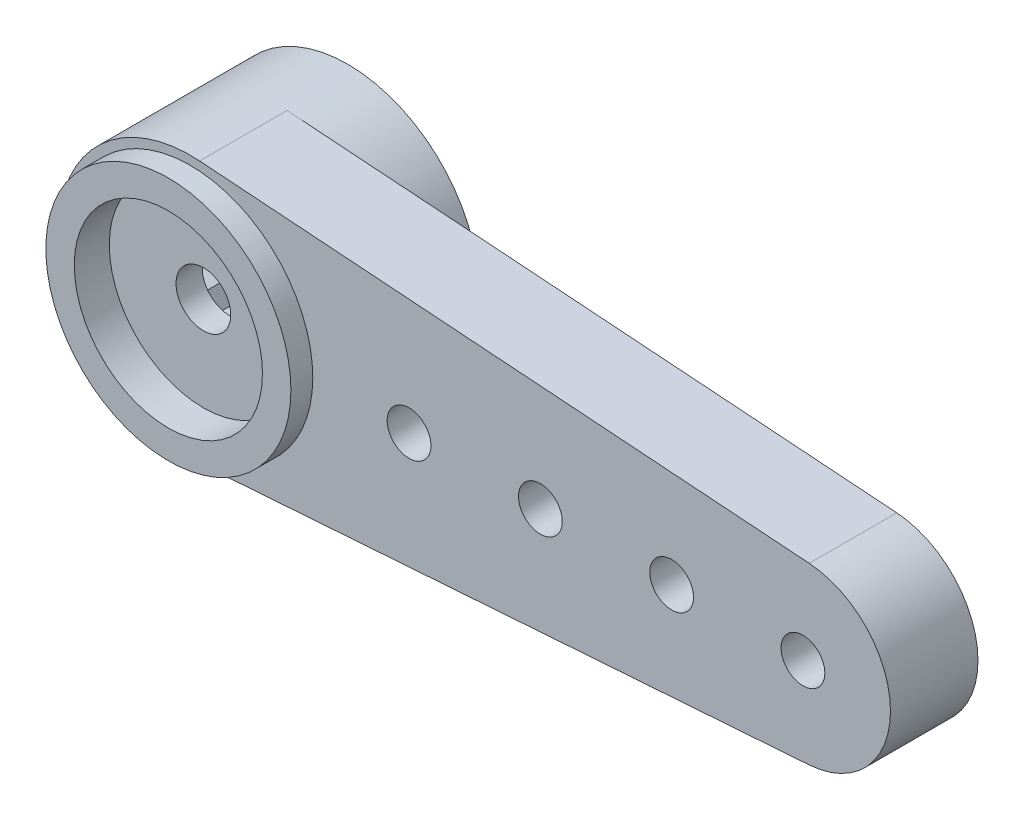
from build123d import *

# Parameters (mm, degrees)
SKETCH2_R           = 3
SKETCH2_R_2         = 2.8
BOSS_EXTRUDE1_DEPTH = 3.6
SKETCH2_3_R         = 2.8
SKETCH2_3_R_2       = 2.15
BOSS_EXTRUDE2_DEPTH = 4.1
BOSS_EXTRUDE3_START = 2.7
SKETCH2_4_R         = 2.15
SKETCH2_4_R_2       = 0.625
BOSS_EXTRUDE3_DEPTH = 0.6
SKETCH2_5_R         = 2.15
BOSS_EXTRUDE4_DEPTH = 2.7
BOSS_EXTRUDE5_START = 3.6
SKETCH2_6_R         = 0.5
BOSS_EXTRUDE5_DEPTH = 2


with BuildPart() as part:
    # Sketch2 → Boss-Extrude1 (new body)
    with BuildSketch(Plane.XY):
        Circle(SKETCH2_R)
        Circle(SKETCH2_R_2, mode=Mode.SUBTRACT)
    extrude(amount=BOSS_EXTRUDE1_DEPTH)

    # Sketch2_3 → Boss-Extrude2 (add)
    with BuildSketch(Plane.XY):
        Circle(SKETCH2_3_R)
        Circle(SKETCH2_3_R_2, mode=Mode.SUBTRACT)
    extrude(amount=BOSS_EXTRUDE2_DEPTH)

    # Sketch2_4 → Boss-Extrude3 (add)
    with BuildSketch(Plane.XY.offset(BOSS_EXTRUDE3_START)):
        Circle(SKETCH2_4_R)
        Circle(SKETCH2_4_R_2, mode=Mode.SUBTRACT)
    extrude(amount=BOSS_EXTRUDE3_DEPTH)

    # Sketch2_5 → Boss-Extrude4 (add)
    with BuildSketch(Plane.XY):
        Circle(SKETCH2_5_R)
        Polygon((-0.374241043, 1.760665681), (0, 2), (0.374241043, 1.760665681), (0.813473286, 1.827090915), (1.058013454, 1.45623059), (1.486289651, 1.338261213), (1.558845727, 0.9), (1.902113033, 0.618033989), (1.790139412, 0.188151234), (1.989043791, -0.209056927), (1.711901729, -0.55623059), (1.732050808, -1), (1.337660686, -1.204435091), (1.175570505, -1.618033989), (0.732125958, -1.644381824), (0.415823382, -1.956295201), (0, -1.8), (-0.415823382, -1.956295201), (-0.732125958, -1.644381824), (-1.175570505, -1.618033989), (-1.337660686, -1.204435091), (-1.732050808, -1), (-1.711901729, -0.55623059), (-1.989043791, -0.209056927), (-1.790139412, 0.188151234), (-1.902113033, 0.618033989), (-1.558845727, 0.9), (-1.486289651, 1.338261213), (-1.058013454, 1.45623059), (-0.813473286, 1.827090915), align=None, mode=Mode.SUBTRACT)
    extrude(amount=BOSS_EXTRUDE4_DEPTH)

    # Sketch2_6 → Boss-Extrude5 (add)
    with BuildSketch(Plane.XY.offset(BOSS_EXTRUDE5_START)):
        with BuildLine():
            Line((14.142857143, 1.994891435), (0.214285714, 2.992337152))
            ThreePointArc((0.214285714, 2.992337152), (3, 0), (0.214285714, -2.992337152))
            Line((0.214285714, -2.992337152), (14.142857143, -1.994891435))
            ThreePointArc((14.142857143, -1.994891435), (16, 0), (14.142857143, 1.994891435))
        make_face()
        with Locations((5, 0)):
            Circle(SKETCH2_6_R, mode=Mode.SUBTRACT)
        with Locations((8, 0)):
            Circle(SKETCH2_6_R, mode=Mode.SUBTRACT)
        with Locations((11, 0)):
            Circle(SKETCH2_6_R, mode=Mode.SUBTRACT)
        with Locations((14, 0)):
            Circle(SKETCH2_6_R, mode=Mode.SUBTRACT)
    extrude(amount=-BOSS_EXTRUDE5_DEPTH)


solid = part.part
